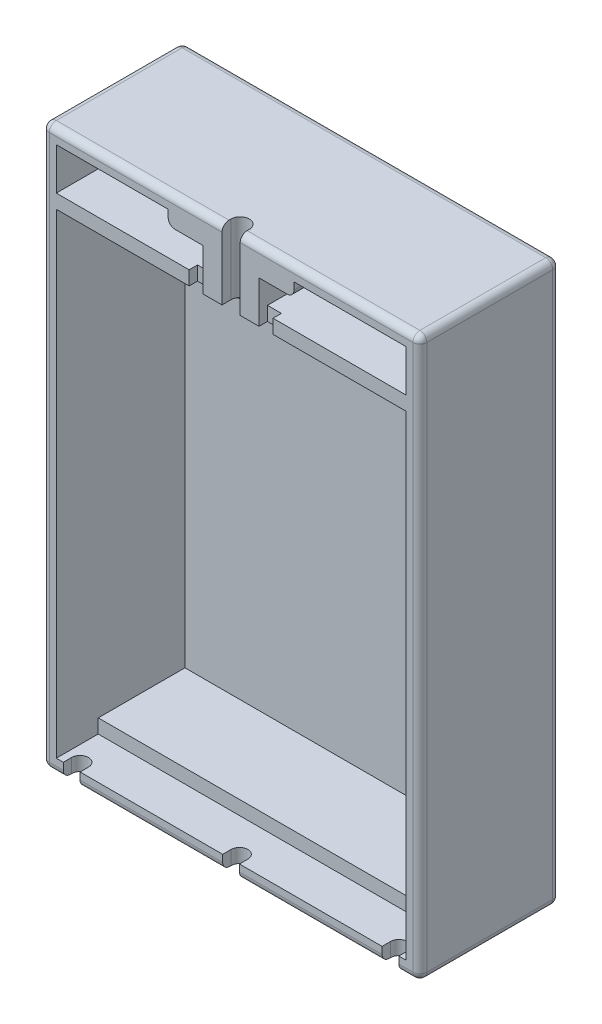
from build123d import *

# Parameters (mm, degrees)
SKETCH_1_W           = 27
SKETCH_1_H           = 40
EXTRUDE_1_DEPTH      = 10
SKETCH_2_W           = 25
SKETCH_2_H           = 31
CUT_EXTRUDE_1_DEPTH  = 9.2
CUT_EXTRUDE_2_DEPTH  = 9
SKETCH_8_W           = 25
SKETCH_8_H           = 2
SKETCH_8_H_2         = 1
CUT_EXTRUDE_7_DEPTH  = 3
SKETCH_9_W           = 8
SKETCH_9_H           = 2
CUT_EXTRUDE_8_DEPTH  = 6.2
CUT_EXTRUDE_9_DEPTH  = 0.65
SKETCH_10_3_W        = 1.2
SKETCH_10_3_H        = 1
CUT_EXTRUDE_10_DEPTH = 0.6
SKETCH_11_R          = 0.65
CUT_EXTRUDE_11_DEPTH = 6
SKETCH_12_R          = 0.6
CUT_EXTRUDE_12_DEPTH = 2
SKETCH_13_W          = 1
SKETCH_13_H          = 1
CUT_EXTRUDE_13_DEPTH = 0.6
FILLET_1_R           = 0.5
FILLET_2_R           = 0.5
FILLET_4_R           = 0.5
FILLET_5_R           = 0.5


with BuildPart() as part:
    # Sketch 1 → Extrude 1 (new body)
    with BuildSketch(Plane.XY):
        with Locations((13.5, 20)):
            Rectangle(SKETCH_1_W, SKETCH_1_H)
    extrude(amount=EXTRUDE_1_DEPTH)

    # Sketch 2 → Cut-Extrude 1 (cut)
    with BuildSketch(Plane.XY.offset(10)):
        with Locations((13.5, 17.5)):
            Rectangle(SKETCH_2_W, SKETCH_2_H)
    extrude(amount=-CUT_EXTRUDE_1_DEPTH, mode=Mode.SUBTRACT)

    # Sketch 3 → Cut-Extrude 2 (cut)
    with BuildSketch(Plane.XY.offset(10)):
        Polygon((1, 39), (9, 39), (9, 38), (11.5, 38), (11.5, 36), (9, 36), (1, 36), align=None)
        Polygon((15.5, 36), (15.5, 38), (18, 38), (18, 39), (26, 39), (26, 36), (18, 36), align=None)
    extrude(amount=-CUT_EXTRUDE_2_DEPTH, mode=Mode.SUBTRACT)

    # Sketch 8 → Cut-Extrude 7 (cut)
    with BuildSketch(Plane.XY.offset(10)):
        with Locations((13.5, 34)):
            Rectangle(SKETCH_8_W, SKETCH_8_H)
        with Locations((13.5, 1.5)):
            Rectangle(SKETCH_8_W, SKETCH_8_H_2)
    extrude(amount=-CUT_EXTRUDE_7_DEPTH, mode=Mode.SUBTRACT)

    # Sketch 9 → Cut-Extrude 8 (cut)
    with BuildSketch(Plane.XY.offset(7)):
        with Locations((5, 34)):
            Rectangle(SKETCH_9_W, SKETCH_9_H)
        with Locations((22, 34)):
            Rectangle(SKETCH_9_W, SKETCH_9_H)
    extrude(amount=-CUT_EXTRUDE_8_DEPTH, mode=Mode.SUBTRACT)

    # Sketch 10 → Cut-Extrude 9 (cut)
    with BuildSketch(Plane.XY.offset(10)):
        Polygon((14.15, 40), (13.5, 40), (12.85, 40), (12.85, 35), (13.5, 35), (14.15, 35), align=None)
    extrude(amount=-CUT_EXTRUDE_9_DEPTH, mode=Mode.SUBTRACT)

    # Sketch 10_3 → Cut-Extrude 10 (cut)
    with BuildSketch(Plane.XY.offset(10)):
        Polygon((12.9, 0), (13.5, 0), (14.1, 0), (14.1, 1), (13.5, 1), (12.9, 1), align=None)
        with Locations((2.1, 0.5)):
            Rectangle(SKETCH_10_3_W, SKETCH_10_3_H)
        with Locations((24.9, 0.5)):
            Rectangle(SKETCH_10_3_W, SKETCH_10_3_H)
    extrude(amount=-CUT_EXTRUDE_10_DEPTH, mode=Mode.SUBTRACT)

    # Sketch 11 → Cut-Extrude 11 (cut, through all)
    with BuildSketch(Plane.XZ.offset(-35)):
        with Locations((13.5, 9.35)):
            Circle(SKETCH_11_R)
    extrude(amount=-CUT_EXTRUDE_11_DEPTH, mode=Mode.SUBTRACT)

    # Sketch 12 → Cut-Extrude 12 (cut, through all)
    with BuildSketch(Plane(origin=(0, 1, 0), x_dir=(1, 0, 0), z_dir=(0, 1, 0))):
        with Locations((13.5, -9.4)):
            Circle(SKETCH_12_R)
        with Locations((24.9, -9.4)):
            Circle(SKETCH_12_R)
        with Locations((2.1, -9.4)):
            Circle(SKETCH_12_R)
    extrude(amount=-CUT_EXTRUDE_12_DEPTH, mode=Mode.SUBTRACT)

    # Sketch 13 → Cut-Extrude 13 (cut)
    with BuildSketch(Plane.XY.offset(10)):
        with Locations((11, 35.5)):
            Rectangle(SKETCH_13_W, SKETCH_13_H)
        with Locations((16, 35.5)):
            Rectangle(SKETCH_13_W, SKETCH_13_H)
    extrude(amount=-CUT_EXTRUDE_13_DEPTH, mode=Mode.SUBTRACT)

    # Fillet 1
    fillet_1_edges = [part.edges().sort_by_distance(p)[0] for p in [
        (18, 33, 3.9),
        (9, 33, 3.9),
    ]]
    fillet(fillet_1_edges, radius=FILLET_1_R)

    # Fillet 2
    fillet_2_edges = [part.edges().sort_by_distance(p)[0] for p in [
        (13.5, 40, 0),
        (27, 20, 0),
        (13.5, 0, 0),
        (0, 20, 0),
        (0, 40, 5),
        (27, 40, 5),
        (27, 0, 5),
        (0, 0, 5),
    ]]
    fillet(fillet_2_edges, radius=FILLET_2_R)

    # Fillet 4
    fillet_4_edges = [part.edges().sort_by_distance(p)[0] for p in [
        (9, 38, 5.5),
        (18, 38, 5.5),
    ]]
    fillet(fillet_4_edges, radius=FILLET_4_R)

    # Fillet 5
    fillet_5_edges = [part.edges().sort_by_distance(p)[0] for p in [
        (6.675, 40, 10),
        (19.2, 0, 10),
        (26, 0, 10),
        (7.8, 0, 10),
        (0, 20, 10),
        (20.325, 40, 10),
        (1, 0, 10),
        (0.146446609, 0.146446609, 10),
        (0.146446609, 39.853553391, 10),
        (27, 20, 10),
        (26.853553391, 0.146446609, 10),
        (26.853553391, 39.853553391, 10),
    ]]
    fillet(fillet_5_edges, radius=FILLET_5_R)


solid = part.part
